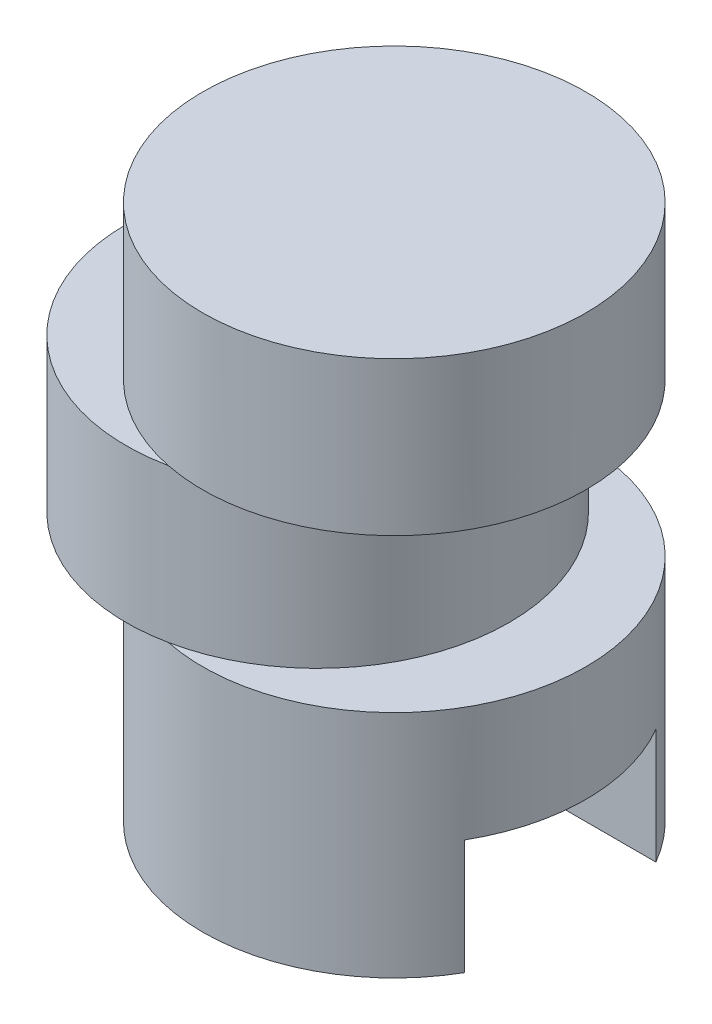
from build123d import *

# Parameters (mm, degrees)
SKETCH_1_R          = 5
EXTRUDE_1_DEPTH     = 6
EXTRUDE_START       = 6
SKETCH_1_3_R        = 5
EXTRUDE_2_DEPTH     = 4
EXTRUDE_START_2     = 10
SKETCH_1_4_R        = 5
EXTRUDE_3_DEPTH     = 4
CUT_EXTRUDE_1_DEPTH = 3


with BuildPart() as part:
    # 草图1 → 凸台-拉伸1 (new body)
    with BuildSketch(Plane(origin=(0, 0, 0), x_dir=(1, 0, 0), z_dir=(0, 1, 0))):
        Circle(SKETCH_1_R)
    extrude(amount=EXTRUDE_1_DEPTH)

    # 草图1<3> → 凸台-拉伸2 (add)
    with BuildSketch(Plane(origin=(0, 0, 0), x_dir=(1, 0, 0), z_dir=(0, 1, 0)).offset(EXTRUDE_START)):
        with Locations((-2, 0)):
            Circle(SKETCH_1_3_R)
    extrude(amount=EXTRUDE_2_DEPTH)

    # 草图1<4> → 凸台-拉伸3 (add)
    with BuildSketch(Plane(origin=(0, 0, 0), x_dir=(1, 0, 0), z_dir=(0, 1, 0)).offset(EXTRUDE_START_2)):
        Circle(SKETCH_1_4_R)
    extrude(amount=EXTRUDE_3_DEPTH)

    # 草图2 → 切除-拉伸1 (cut)
    with BuildSketch(Plane.XZ):
        with BuildLine():
            Line((-4.330127019, 2.5), (4.330127019, 2.5))
            ThreePointArc((4.330127019, 2.5), (5, 0), (4.330127019, -2.5))
            Line((4.330127019, -2.5), (-4.330127019, -2.5))
            ThreePointArc((-4.330127019, -2.5), (-5, 0), (-4.330127019, 2.5))
        make_face()
    extrude(amount=-CUT_EXTRUDE_1_DEPTH, mode=Mode.SUBTRACT)


solid = part.part
